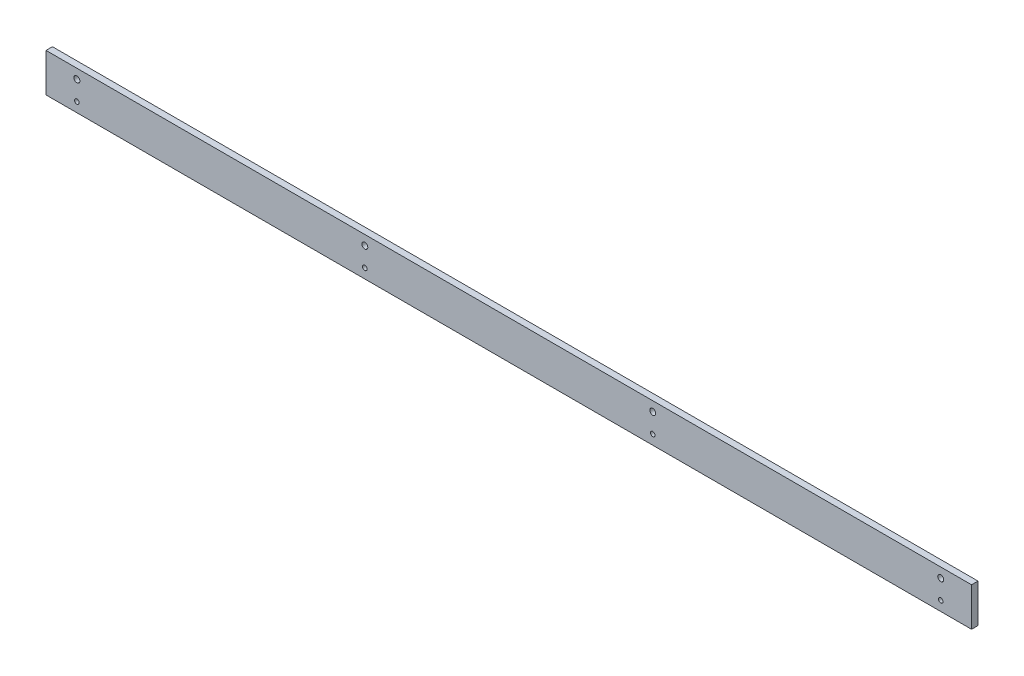
from build123d import *

# Parameters (mm, degrees)
SKETCH1_W             = 457.2
SKETCH1_H             = 19.05
BOSS_EXTRUDE1_DEPTH   = 3.175
F_4_CLEARANCE_HOLE1_D = 2.9464
F_4_40_TAPPED_HOLE1_D = 2.2606


with BuildPart() as part:
    # Sketch1 → Boss-Extrude1 (new body)
    with BuildSketch(Plane.XY):
        Rectangle(SKETCH1_W, SKETCH1_H)
    extrude(amount=BOSS_EXTRUDE1_DEPTH)

    # #4 Clearance Hole1 (through all)
    with Locations(Plane.XY.offset(3.175)):
        with Locations((-213.36, 4.7625), (-71.12, 4.7625), (71.12, 4.7625), (213.36, 4.7625)):
            Hole(F_4_CLEARANCE_HOLE1_D / 2)

    # #4-40 Tapped Hole1 (through all)
    with Locations(Plane.XY.offset(3.175)):
        with Locations((-213.36, -4.7625), (-71.12, -4.7625), (71.12, -4.7625), (213.36, -4.7625)):
            Hole(F_4_40_TAPPED_HOLE1_D / 2)


solid = part.part
